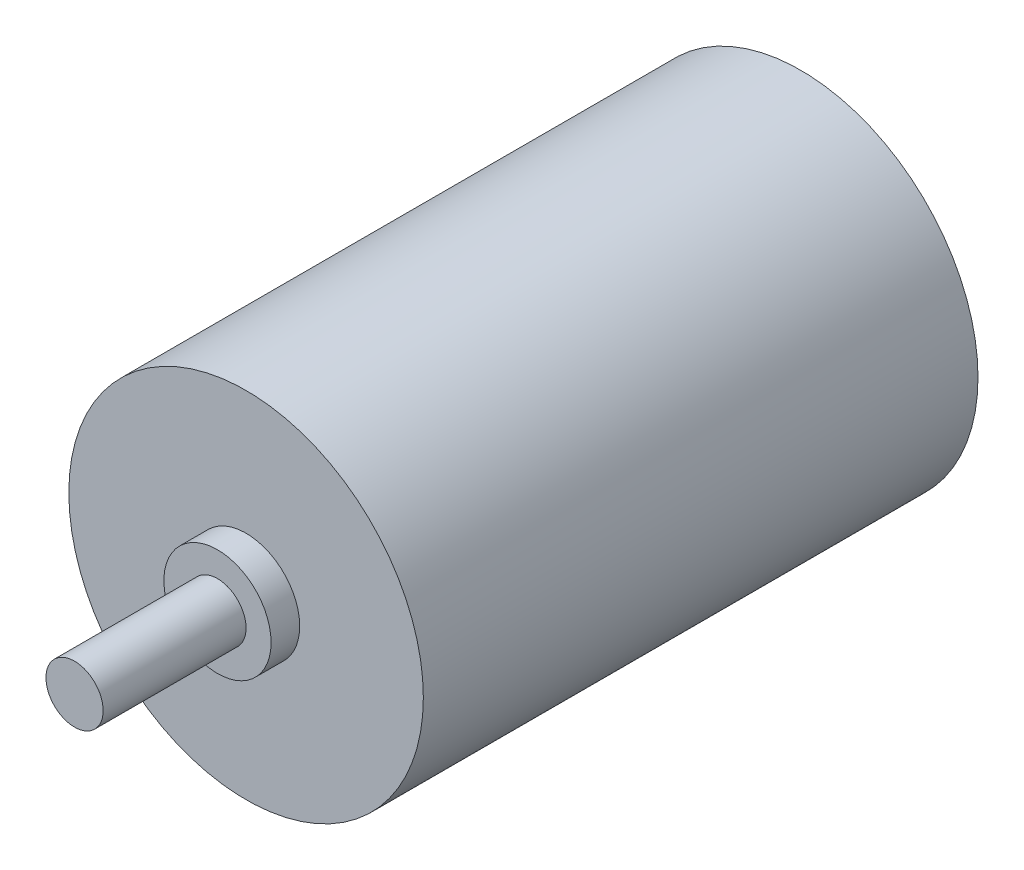
from build123d import *

# Parameters (mm, degrees)
SKIZZE1_R                       = 12.4
AUFSATZ_LINEAR_AUSTRAGEN1_DEPTH = 38.8
SKIZZE2_R                       = 3.75
AUFSATZ_LINEAR_AUSTRAGEN2_DEPTH = 2
SKIZZE3_R                       = 2
AUFSATZ_LINEAR_AUSTRAGEN3_DEPTH = 10
SKIZZE4_W                       = 7
SKIZZE4_H                       = 2
AUFSATZ_LINEAR_AUSTRAGEN4_DEPTH = 3


with BuildPart() as part:
    # Skizze1 → Aufsatz-Linear austragen1 (new body)
    with BuildSketch(Plane.XY):
        Circle(SKIZZE1_R)
    extrude(amount=AUFSATZ_LINEAR_AUSTRAGEN1_DEPTH)

    # Skizze2 → Aufsatz-Linear austragen2 (add)
    with BuildSketch(Plane.XY.offset(38.8)):
        Circle(SKIZZE2_R)
    extrude(amount=AUFSATZ_LINEAR_AUSTRAGEN2_DEPTH)

    # Skizze3 → Aufsatz-Linear austragen3 (add)
    with BuildSketch(Plane.XY.offset(40.8)):
        Circle(SKIZZE3_R)
    extrude(amount=AUFSATZ_LINEAR_AUSTRAGEN3_DEPTH)

    # Skizze4 → Aufsatz-Linear austragen4 (add)
    with BuildSketch(Plane(origin=(0, 0, 0), x_dir=(-1, 0, 0), z_dir=(0, 0, -1))):
        with Locations((0, -9)):
            Rectangle(SKIZZE4_W, SKIZZE4_H)
    extrude(amount=AUFSATZ_LINEAR_AUSTRAGEN4_DEPTH)


solid = part.part
